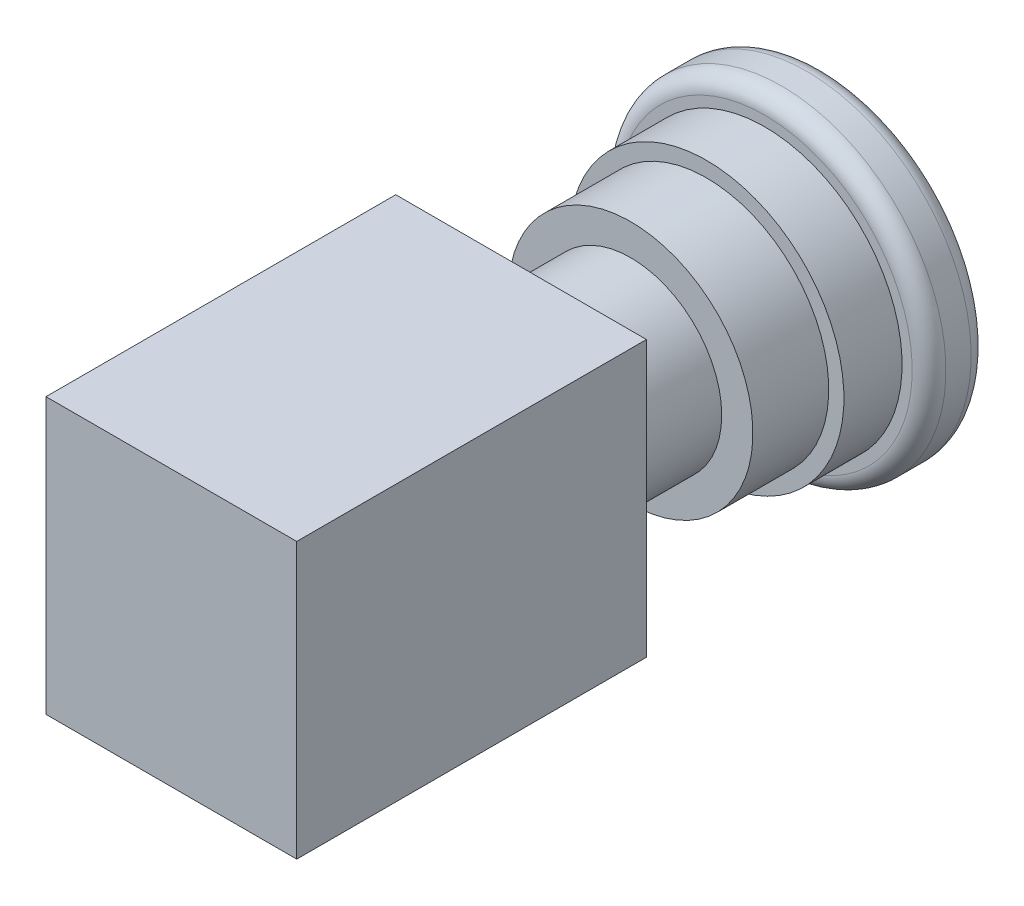
from build123d import *

# Parameters (mm, degrees)
SKETCH1_R           = 10.8
BOSS_EXTRUDE1_DEPTH = 13
SKETCH2_R           = 14.5
BOSS_EXTRUDE2_DEPTH = 9
SKETCH3_R           = 16.3
BOSS_EXTRUDE3_DEPTH = 6.9
SKETCH4_R           = 19.5
BOSS_EXTRUDE4_DEPTH = 7
FILLET1_R           = 2
SKETCH5_W           = 29.75
SKETCH5_H           = 32.65
BOSS_EXTRUDE5_DEPTH = 41.5


with BuildPart() as part:
    # Sketch1 → Boss-Extrude1 (new body)
    with BuildSketch(Plane.XY):
        Circle(SKETCH1_R)
    extrude(amount=BOSS_EXTRUDE1_DEPTH)

    # Sketch2 → Boss-Extrude2 (add)
    with BuildSketch(Plane(origin=(0, 0, 0), x_dir=(-1, 0, 0), z_dir=(0, 0, -1))):
        Circle(SKETCH2_R)
    extrude(amount=BOSS_EXTRUDE2_DEPTH)

    # Sketch3 → Boss-Extrude3 (add)
    with BuildSketch(Plane(origin=(0, 0, -9), x_dir=(-1, 0, 0), z_dir=(0, 0, -1))):
        Circle(SKETCH3_R)
    extrude(amount=BOSS_EXTRUDE3_DEPTH)

    # Sketch4 → Boss-Extrude4 (add)
    with BuildSketch(Plane(origin=(0, 0, -15.9), x_dir=(-1, 0, 0), z_dir=(0, 0, -1))):
        Circle(SKETCH4_R)
    extrude(amount=BOSS_EXTRUDE4_DEPTH)

    # Fillet1
    fillet1_edges = [part.edges().sort_by_distance(p)[0] for p in [
        (19.5, 0, -15.9),
        (19.5, 0, -22.9),
    ]]
    fillet(fillet1_edges, radius=FILLET1_R)

    # Sketch5 → Boss-Extrude5 (add)
    with BuildSketch(Plane.XY.offset(13)):
        Rectangle(SKETCH5_W, SKETCH5_H)
    extrude(amount=BOSS_EXTRUDE5_DEPTH)


solid = part.part
